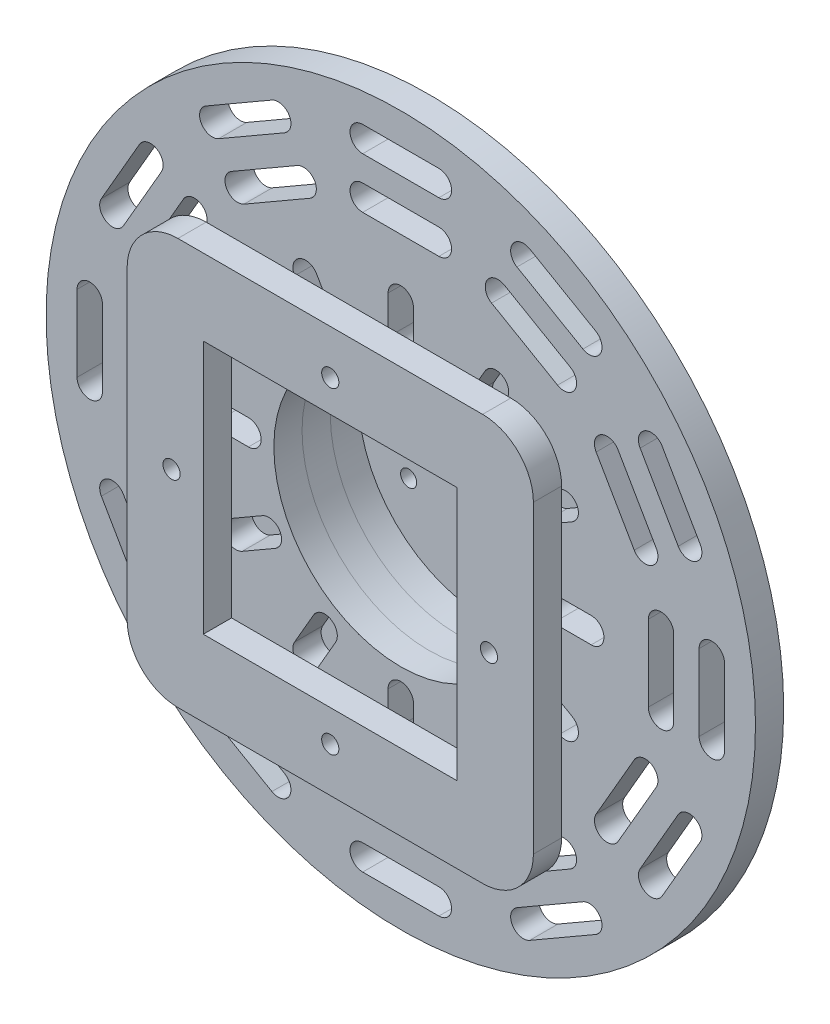
from build123d import *

# Parameters (mm, degrees)
SKETCH4_R           = 75
SKETCH4_R_2         = 12.7
SKETCH4_R_3         = 3.175
BOSS_EXTRUDE1_DEPTH = 11.1125
SKETCH5_R           = 75
SKETCH5_R_2         = 50
BOSS_EXTRUDE2_DEPTH = 11.1125
SKETCH6_R           = 90
SKETCH6_R_2         = 50
BOSS_EXTRUDE3_DEPTH = 11.1125
SKETCH7_R           = 139.7
SKETCH7_R_2         = 50
BOSS_EXTRUDE4_DEPTH = 11.1125
BOSS_EXTRUDE5_START = 50
SKETCH8_R           = 3.3782
SKETCH8_W           = 100
SKETCH8_H           = 100
BOSS_EXTRUDE5_DEPTH = 11.1125
SKETCH10_R          = 3.3782
CUT_EXTRUDE1_DEPTH  = 11.1125


with BuildPart() as part:
    # Sketch4 → Boss-Extrude1 (new body)
    with BuildSketch(Plane.XY):
        Circle(SKETCH4_R)
        Circle(SKETCH4_R_2, mode=Mode.SUBTRACT)
        with Locations((30.245937227, 17.4625)):
            Circle(SKETCH4_R_3, mode=Mode.SUBTRACT)
        with Locations((-30.245937227, 17.4625)):
            Circle(SKETCH4_R_3, mode=Mode.SUBTRACT)
        with Locations((0, -34.925)):
            Circle(SKETCH4_R_3, mode=Mode.SUBTRACT)
        with BuildLine():
            ThreePointArc((-2.24506403, 37.17006403), (1.029072671, 31.921396425), (0.396601421, 38.07513211))
            ThreePointArc((0.396601421, 38.07513211), (-1.029072671, 37.928603575), (-2.24506403, 37.17006403))
        make_face(mode=Mode.SUBTRACT)
        with BuildLine():
            ThreePointArc((-31.067687695, -20.529314498), (-28.159276563, -15.069495137), (-33.17233237, -18.69409915))
            ThreePointArc((-33.17233237, -18.69409915), (-32.332597891, -19.855504863), (-31.067687695, -20.529314498))
        make_face(mode=Mode.SUBTRACT)
        with BuildLine():
            ThreePointArc((33.312751726, -16.640749532), (27.130203893, -16.851901288), (32.77573095, -19.381032961))
            ThreePointArc((32.77573095, -19.381032961), (33.361670562, -18.073098712), (33.312751726, -16.640749532))
        make_face(mode=Mode.SUBTRACT)
    extrude(amount=BOSS_EXTRUDE1_DEPTH)

    # Sketch10 → Cut-Extrude1 (cut)
    with BuildSketch(Plane.XY.offset(11.1125)):
        with Locations((62.5, 0)):
            Circle(SKETCH10_R)
        with Locations((0, 62.5)):
            Circle(SKETCH10_R)
        with Locations((0, -62.5)):
            Circle(SKETCH10_R)
        with Locations((-62.5, 0)):
            Circle(SKETCH10_R)
    extrude(amount=-CUT_EXTRUDE1_DEPTH, mode=Mode.SUBTRACT)


with BuildPart() as body_2:
    # Sketch5 → Boss-Extrude2 (new body)
    with BuildSketch(Plane.XY.offset(11.1125)):
        Circle(SKETCH5_R)
        Circle(SKETCH5_R_2, mode=Mode.SUBTRACT)
    extrude(amount=BOSS_EXTRUDE2_DEPTH)


with BuildPart() as body_3:
    # Sketch6 → Boss-Extrude3 (new body)
    with BuildSketch(Plane.XY.offset(22.225)):
        Circle(SKETCH6_R)
        Circle(SKETCH6_R_2, mode=Mode.SUBTRACT)
    extrude(amount=BOSS_EXTRUDE3_DEPTH)


with BuildPart() as body_4:
    # Sketch7 → Boss-Extrude4 (new body)
    with BuildSketch(Plane.XY.offset(33.3375)):
        Circle(SKETCH7_R)
        Circle(SKETCH7_R_2, mode=Mode.SUBTRACT)
        with BuildLine():
            Line((-5, -60), (-5, -75))
            ThreePointArc((-5, -75), (0, -80), (5, -75))
            Line((5, -75), (5, -60))
            ThreePointArc((5, -60), (0, -55), (-5, -60))
        make_face(mode=Mode.SUBTRACT)
        with BuildLine():
            Line((15, -117.5), (-15, -117.5))
            ThreePointArc((-15, -117.5), (-20, -122.5), (-15, -127.5))
            Line((-15, -127.5), (15, -127.5))
            ThreePointArc((15, -127.5), (20, -122.5), (15, -117.5))
        make_face(mode=Mode.SUBTRACT)
        with BuildLine():
            Line((-45.759618943, -109.257984945), (-71.740381057, -94.257984945))
            ThreePointArc((-71.740381057, -94.257984945), (-78.570508076, -96.088111964), (-76.740381057, -102.918238983))
            Line((-76.740381057, -102.918238983), (-50.759618943, -117.918238983))
            ThreePointArc((-50.759618943, -117.918238983), (-43.929491924, -116.088111964), (-45.759618943, -109.257984945))
        make_face(mode=Mode.SUBTRACT)
        with BuildLine():
            Line((-33.169872981, -67.451905284), (-25.669872981, -54.461524227))
            ThreePointArc((-25.669872981, -54.461524227), (-27.5, -47.631397208), (-34.330127019, -49.461524227))
            Line((-34.330127019, -49.461524227), (-41.830127019, -62.451905284))
            ThreePointArc((-41.830127019, -62.451905284), (-40, -69.282032303), (-33.169872981, -67.451905284))
        make_face(mode=Mode.SUBTRACT)
        with BuildLine():
            Line((-54.461524227, -25.669872981), (-67.451905284, -33.169872981))
            ThreePointArc((-67.451905284, -33.169872981), (-69.282032303, -40), (-62.451905284, -41.830127019))
            Line((-62.451905284, -41.830127019), (-49.461524227, -34.330127019))
            ThreePointArc((-49.461524227, -34.330127019), (-47.631397208, -27.5), (-54.461524227, -25.669872981))
        make_face(mode=Mode.SUBTRACT)
        with BuildLine():
            Line((-35.759618943, -91.937476869), (-61.740381057, -76.937476869))
            ThreePointArc((-61.740381057, -76.937476869), (-68.570508076, -78.767603888), (-66.740381057, -85.597730907))
            Line((-66.740381057, -85.597730907), (-40.759618943, -100.597730907))
            ThreePointArc((-40.759618943, -100.597730907), (-33.929491924, -98.767603888), (-35.759618943, -91.937476869))
        make_face(mode=Mode.SUBTRACT)
        with BuildLine():
            Line((-94.257984945, -71.740381057), (-109.257984945, -45.759618943))
            ThreePointArc((-109.257984945, -45.759618943), (-116.088111964, -43.929491924), (-117.918238983, -50.759618943))
            Line((-117.918238983, -50.759618943), (-102.918238983, -76.740381057))
            ThreePointArc((-102.918238983, -76.740381057), (-96.088111964, -78.570508076), (-94.257984945, -71.740381057))
        make_face(mode=Mode.SUBTRACT)
        with BuildLine():
            Line((-76.937476869, -61.740381057), (-91.937476869, -35.759618943))
            ThreePointArc((-91.937476869, -35.759618943), (-98.767603888, -33.929491924), (-100.597730907, -40.759618943))
            Line((-100.597730907, -40.759618943), (-85.597730907, -66.740381057))
            ThreePointArc((-85.597730907, -66.740381057), (-78.767603888, -68.570508076), (-76.937476869, -61.740381057))
        make_face(mode=Mode.SUBTRACT)
        with BuildLine():
            Line((-75, -5), (-60, -5))
            ThreePointArc((-60, -5), (-55, 0), (-60, 5))
            Line((-60, 5), (-75, 5))
            ThreePointArc((-75, 5), (-80, 0), (-75, -5))
        make_face(mode=Mode.SUBTRACT)
        with BuildLine():
            Line((-15, -107.5), (15, -107.5))
            ThreePointArc((15, -107.5), (20, -102.5), (15, -97.5))
            Line((15, -97.5), (-15, -97.5))
            ThreePointArc((-15, -97.5), (-20, -102.5), (-15, -107.5))
        make_face(mode=Mode.SUBTRACT)
        with BuildLine():
            Line((-49.461524227, 34.330127019), (-62.451905284, 41.830127019))
            ThreePointArc((-62.451905284, 41.830127019), (-69.282032303, 40), (-67.451905284, 33.169872981))
            Line((-67.451905284, 33.169872981), (-54.461524227, 25.669872981))
            ThreePointArc((-54.461524227, 25.669872981), (-47.631397208, 27.5), (-49.461524227, 34.330127019))
        make_face(mode=Mode.SUBTRACT)
        with BuildLine():
            Line((-127.5, 15), (-127.5, -15))
            ThreePointArc((-127.5, -15), (-122.5, -20), (-117.5, -15))
            Line((-117.5, -15), (-117.5, 15))
            ThreePointArc((-117.5, 15), (-122.5, 20), (-127.5, 15))
        make_face(mode=Mode.SUBTRACT)
        with BuildLine():
            Line((-97.5, -15), (-97.5, 15))
            ThreePointArc((-97.5, 15), (-102.5, 20), (-107.5, 15))
            Line((-107.5, 15), (-107.5, -15))
            ThreePointArc((-107.5, -15), (-102.5, -20), (-97.5, -15))
        make_face(mode=Mode.SUBTRACT)
        with BuildLine():
            Line((-109.257984945, 45.759618943), (-94.257984945, 71.740381057))
            ThreePointArc((-94.257984945, 71.740381057), (-96.088111964, 78.570508076), (-102.918238983, 76.740381057))
            Line((-102.918238983, 76.740381057), (-117.918238983, 50.759618943))
            ThreePointArc((-117.918238983, 50.759618943), (-116.088111964, 43.929491924), (-109.257984945, 45.759618943))
        make_face(mode=Mode.SUBTRACT)
        with BuildLine():
            Line((-91.937476869, 35.759618943), (-76.937476869, 61.740381057))
            ThreePointArc((-76.937476869, 61.740381057), (-78.767603888, 68.570508076), (-85.597730907, 66.740381057))
            Line((-85.597730907, 66.740381057), (-100.597730907, 40.759618943))
            ThreePointArc((-100.597730907, 40.759618943), (-98.767603888, 33.929491924), (-91.937476869, 35.759618943))
        make_face(mode=Mode.SUBTRACT)
        with BuildLine():
            Line((-71.740381057, 94.257984945), (-45.759618943, 109.257984945))
            ThreePointArc((-45.759618943, 109.257984945), (-43.929491924, 116.088111964), (-50.759618943, 117.918238983))
            Line((-50.759618943, 117.918238983), (-76.740381057, 102.918238983))
            ThreePointArc((-76.740381057, 102.918238983), (-78.570508076, 96.088111964), (-71.740381057, 94.257984945))
        make_face(mode=Mode.SUBTRACT)
        with BuildLine():
            Line((-25.669872981, 54.461524227), (-33.169872981, 67.451905284))
            ThreePointArc((-33.169872981, 67.451905284), (-40, 69.282032303), (-41.830127019, 62.451905284))
            Line((-41.830127019, 62.451905284), (-34.330127019, 49.461524227))
            ThreePointArc((-34.330127019, 49.461524227), (-27.5, 47.631397208), (-25.669872981, 54.461524227))
        make_face(mode=Mode.SUBTRACT)
        with BuildLine():
            Line((5, 60), (5, 75))
            ThreePointArc((5, 75), (0, 80), (-5, 75))
            Line((-5, 75), (-5, 60))
            ThreePointArc((-5, 60), (0, 55), (5, 60))
        make_face(mode=Mode.SUBTRACT)
        with BuildLine():
            Line((-61.740381057, 76.937476869), (-35.759618943, 91.937476869))
            ThreePointArc((-35.759618943, 91.937476869), (-33.929491924, 98.767603888), (-40.759618943, 100.597730907))
            Line((-40.759618943, 100.597730907), (-66.740381057, 85.597730907))
            ThreePointArc((-66.740381057, 85.597730907), (-68.570508076, 78.767603888), (-61.740381057, 76.937476869))
        make_face(mode=Mode.SUBTRACT)
        with BuildLine():
            Line((-15, 117.5), (15, 117.5))
            ThreePointArc((15, 117.5), (20, 122.5), (15, 127.5))
            Line((15, 127.5), (-15, 127.5))
            ThreePointArc((-15, 127.5), (-20, 122.5), (-15, 117.5))
        make_face(mode=Mode.SUBTRACT)
        with BuildLine():
            Line((-15, 97.5), (15, 97.5))
            ThreePointArc((15, 97.5), (20, 102.5), (15, 107.5))
            Line((15, 107.5), (-15, 107.5))
            ThreePointArc((-15, 107.5), (-20, 102.5), (-15, 97.5))
        make_face(mode=Mode.SUBTRACT)
        with BuildLine():
            Line((45.759618943, 109.257984945), (71.740381057, 94.257984945))
            ThreePointArc((71.740381057, 94.257984945), (78.570508076, 96.088111964), (76.740381057, 102.918238983))
            Line((76.740381057, 102.918238983), (50.759618943, 117.918238983))
            ThreePointArc((50.759618943, 117.918238983), (43.929491924, 116.088111964), (45.759618943, 109.257984945))
        make_face(mode=Mode.SUBTRACT)
        with BuildLine():
            Line((35.759618943, 91.937476869), (61.740381057, 76.937476869))
            ThreePointArc((61.740381057, 76.937476869), (68.570508076, 78.767603888), (66.740381057, 85.597730907))
            Line((66.740381057, 85.597730907), (40.759618943, 100.597730907))
            ThreePointArc((40.759618943, 100.597730907), (33.929491924, 98.767603888), (35.759618943, 91.937476869))
        make_face(mode=Mode.SUBTRACT)
        with BuildLine():
            Line((34.330127019, 49.461524227), (41.830127019, 62.451905284))
            ThreePointArc((41.830127019, 62.451905284), (40, 69.282032303), (33.169872981, 67.451905284))
            Line((33.169872981, 67.451905284), (25.669872981, 54.461524227))
            ThreePointArc((25.669872981, 54.461524227), (27.5, 47.631397208), (34.330127019, 49.461524227))
        make_face(mode=Mode.SUBTRACT)
        with BuildLine():
            Line((94.257984945, 71.740381057), (109.257984945, 45.759618943))
            ThreePointArc((109.257984945, 45.759618943), (116.088111964, 43.929491924), (117.918238983, 50.759618943))
            Line((117.918238983, 50.759618943), (102.918238983, 76.740381057))
            ThreePointArc((102.918238983, 76.740381057), (96.088111964, 78.570508076), (94.257984945, 71.740381057))
        make_face(mode=Mode.SUBTRACT)
        with BuildLine():
            Line((54.461524227, 25.669872981), (67.451905284, 33.169872981))
            ThreePointArc((67.451905284, 33.169872981), (69.282032303, 40), (62.451905284, 41.830127019))
            Line((62.451905284, 41.830127019), (49.461524227, 34.330127019))
            ThreePointArc((49.461524227, 34.330127019), (47.631397208, 27.5), (54.461524227, 25.669872981))
        make_face(mode=Mode.SUBTRACT)
        with BuildLine():
            Line((60, -5), (75, -5))
            ThreePointArc((75, -5), (80, 0), (75, 5))
            Line((75, 5), (60, 5))
            ThreePointArc((60, 5), (55, 0), (60, -5))
        make_face(mode=Mode.SUBTRACT)
        with BuildLine():
            Line((76.937476869, 61.740381057), (91.937476869, 35.759618943))
            ThreePointArc((91.937476869, 35.759618943), (98.767603888, 33.929491924), (100.597730907, 40.759618943))
            Line((100.597730907, 40.759618943), (85.597730907, 66.740381057))
            ThreePointArc((85.597730907, 66.740381057), (78.767603888, 68.570508076), (76.937476869, 61.740381057))
        make_face(mode=Mode.SUBTRACT)
        with BuildLine():
            Line((49.461524227, -34.330127019), (62.451905284, -41.830127019))
            ThreePointArc((62.451905284, -41.830127019), (69.282032303, -40), (67.451905284, -33.169872981))
            Line((67.451905284, -33.169872981), (54.461524227, -25.669872981))
            ThreePointArc((54.461524227, -25.669872981), (47.631397208, -27.5), (49.461524227, -34.330127019))
        make_face(mode=Mode.SUBTRACT)
        with BuildLine():
            Line((117.5, 15), (117.5, -15))
            ThreePointArc((117.5, -15), (122.5, -20), (127.5, -15))
            Line((127.5, -15), (127.5, 15))
            ThreePointArc((127.5, 15), (122.5, 20), (117.5, 15))
        make_face(mode=Mode.SUBTRACT)
        with BuildLine():
            Line((97.5, 15), (97.5, -15))
            ThreePointArc((97.5, -15), (102.5, -20), (107.5, -15))
            Line((107.5, -15), (107.5, 15))
            ThreePointArc((107.5, 15), (102.5, 20), (97.5, 15))
        make_face(mode=Mode.SUBTRACT)
        with BuildLine():
            Line((109.257984945, -45.759618943), (94.257984945, -71.740381057))
            ThreePointArc((94.257984945, -71.740381057), (96.088111964, -78.570508076), (102.918238983, -76.740381057))
            Line((102.918238983, -76.740381057), (117.918238983, -50.759618943))
            ThreePointArc((117.918238983, -50.759618943), (116.088111964, -43.929491924), (109.257984945, -45.759618943))
        make_face(mode=Mode.SUBTRACT)
        with BuildLine():
            Line((91.937476869, -35.759618943), (76.937476869, -61.740381057))
            ThreePointArc((76.937476869, -61.740381057), (78.767603888, -68.570508076), (85.597730907, -66.740381057))
            Line((85.597730907, -66.740381057), (100.597730907, -40.759618943))
            ThreePointArc((100.597730907, -40.759618943), (98.767603888, -33.929491924), (91.937476869, -35.759618943))
        make_face(mode=Mode.SUBTRACT)
        with BuildLine():
            Line((71.740381057, -94.257984945), (45.759618943, -109.257984945))
            ThreePointArc((45.759618943, -109.257984945), (43.929491924, -116.088111964), (50.759618943, -117.918238983))
            Line((50.759618943, -117.918238983), (76.740381057, -102.918238983))
            ThreePointArc((76.740381057, -102.918238983), (78.570508076, -96.088111964), (71.740381057, -94.257984945))
        make_face(mode=Mode.SUBTRACT)
        with BuildLine():
            Line((61.740381057, -76.937476869), (35.759618943, -91.937476869))
            ThreePointArc((35.759618943, -91.937476869), (33.929491924, -98.767603888), (40.759618943, -100.597730907))
            Line((40.759618943, -100.597730907), (66.740381057, -85.597730907))
            ThreePointArc((66.740381057, -85.597730907), (68.570508076, -78.767603888), (61.740381057, -76.937476869))
        make_face(mode=Mode.SUBTRACT)
        with BuildLine():
            Line((25.669872981, -54.461524227), (33.169872981, -67.451905284))
            ThreePointArc((33.169872981, -67.451905284), (40, -69.282032303), (41.830127019, -62.451905284))
            Line((41.830127019, -62.451905284), (34.330127019, -49.461524227))
            ThreePointArc((34.330127019, -49.461524227), (27.5, -47.631397208), (25.669872981, -54.461524227))
        make_face(mode=Mode.SUBTRACT)
    extrude(amount=BOSS_EXTRUDE4_DEPTH)


with BuildPart() as body_5:
    # Sketch8 → Boss-Extrude5 (new body)
    with BuildSketch(Plane.XY.offset(11.1125).offset(BOSS_EXTRUDE5_START)):
        with BuildLine():
            Line((-60, 80), (60, 80))
            ThreePointArc((60, 80), (74.142135624, 74.142135624), (80, 60))
            Line((80, 60), (80, -60))
            ThreePointArc((80, -60), (74.142135624, -74.142135624), (60, -80))
            Line((60, -80), (-60, -80))
            ThreePointArc((-60, -80), (-74.142135624, -74.142135624), (-80, -60))
            Line((-80, -60), (-80, 60))
            ThreePointArc((-80, 60), (-74.142135624, 74.142135624), (-60, 80))
        make_face()
        with Locations((-62.5, 0)):
            Circle(SKETCH8_R, mode=Mode.SUBTRACT)
        with Locations((0, 62.5)):
            Circle(SKETCH8_R, mode=Mode.SUBTRACT)
        with Locations((62.5, 0)):
            Circle(SKETCH8_R, mode=Mode.SUBTRACT)
        with Locations((0, -62.5)):
            Circle(SKETCH8_R, mode=Mode.SUBTRACT)
        Rectangle(SKETCH8_W, SKETCH8_H, mode=Mode.SUBTRACT)
    extrude(amount=BOSS_EXTRUDE5_DEPTH)


solid = Compound([part.part, body_2.part, body_3.part, body_4.part, body_5.part])
